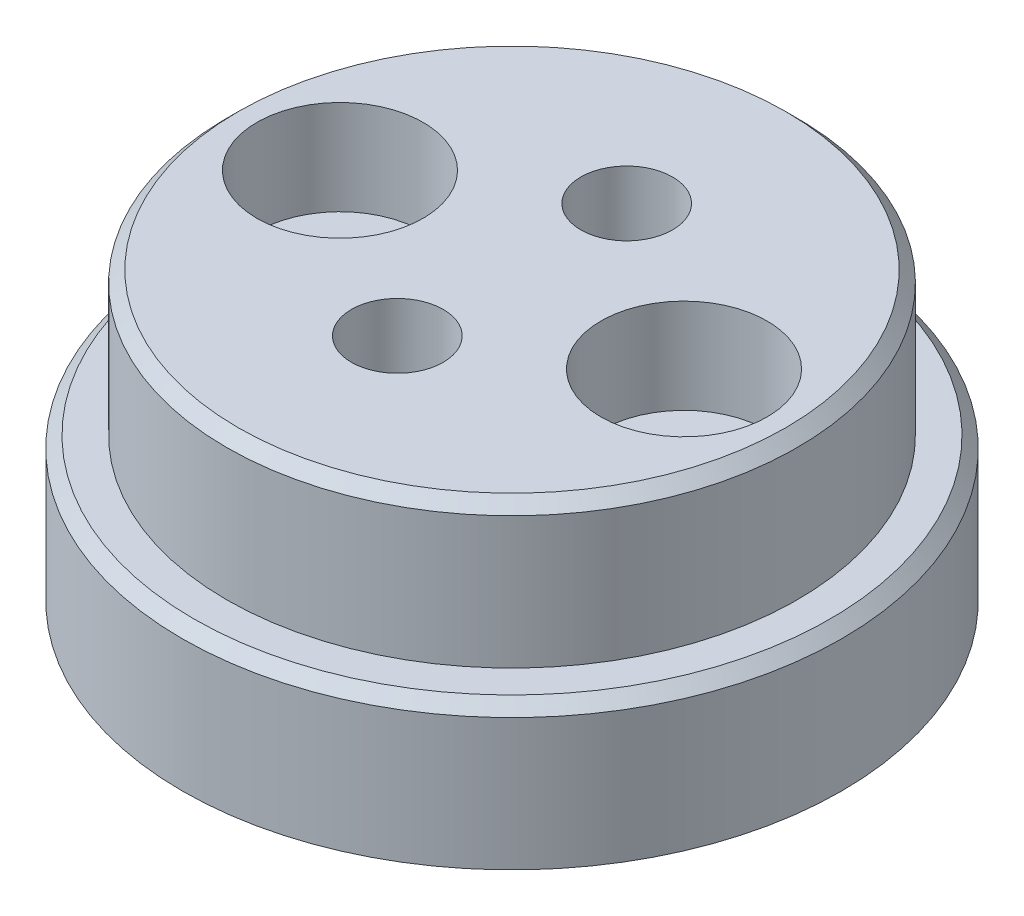
from build123d import *

# Parameters (mm, degrees)
ESQUISSE1_R             = 11.5
ESQUISSE1_R_2           = 1.7
ESQUISSE1_R_3           = 1.6
BOSS_EXTRU_1_DEPTH      = 5
ESQUISSE2_R             = 9.95
ESQUISSE2_R_2           = 1.7
ESQUISSE2_R_3           = 1.6
BOSS_EXTRU_2_DEPTH      = 5
CHANFREIN2_SIZE         = 0.4
CHANFREIN4_SIZE         = 0.4
ESQUISSE3_R             = 2.2
ENL_V_MAT_EXTRU_1_DEPTH = 5.7
ESQUISSE4_R             = 2.9
ENL_V_MAT_EXTRU_2_DEPTH = 3.3


with BuildPart() as part:
    # Esquisse1 → Boss.-Extru.1 (new body)
    with BuildSketch(Plane(origin=(0, 0, 0), x_dir=(1, 0, 0), z_dir=(0, 1, 0))):
        Circle(ESQUISSE1_R)
        with Locations((6, 0)):
            Circle(ESQUISSE1_R_2, mode=Mode.SUBTRACT)
        with Locations((-6, 0)):
            Circle(ESQUISSE1_R_2, mode=Mode.SUBTRACT)
        with Locations((0, 4)):
            Circle(ESQUISSE1_R_3, mode=Mode.SUBTRACT)
        with Locations((0, -4)):
            Circle(ESQUISSE1_R_3, mode=Mode.SUBTRACT)
    extrude(amount=BOSS_EXTRU_1_DEPTH)

    # Esquisse2 → Boss.-Extru.2 (add)
    with BuildSketch(Plane(origin=(0, 5, 0), x_dir=(1, 0, 0), z_dir=(0, 1, 0))):
        Circle(ESQUISSE2_R)
        with Locations((6, 0)):
            Circle(ESQUISSE2_R_2, mode=Mode.SUBTRACT)
        with Locations((-6, 0)):
            Circle(ESQUISSE2_R_2, mode=Mode.SUBTRACT)
        with Locations((0, -4)):
            Circle(ESQUISSE2_R_3, mode=Mode.SUBTRACT)
        with Locations((0, 4)):
            Circle(ESQUISSE2_R_3, mode=Mode.SUBTRACT)
    extrude(amount=BOSS_EXTRU_2_DEPTH)

    # Chanfrein2
    chanfrein2_edges = [part.edges().sort_by_distance(p)[0] for p in [
        (-9.95, 10, 0),
    ]]
    chamfer(chanfrein2_edges, length=CHANFREIN2_SIZE)

    # Chanfrein4
    chanfrein4_edges = [part.edges().sort_by_distance(p)[0] for p in [
        (-11.5, 5, 0),
    ]]
    chamfer(chanfrein4_edges, length=CHANFREIN4_SIZE)

    # Esquisse3 → Enlèv. mat.-Extru.1 (cut)
    with BuildSketch(Plane.XZ):
        with Locations((0, -4)):
            Circle(ESQUISSE3_R)
        with Locations((0, 4)):
            Circle(ESQUISSE3_R)
    extrude(amount=-ENL_V_MAT_EXTRU_1_DEPTH, mode=Mode.SUBTRACT)

    # Esquisse4 → Enlèv. mat.-Extru.2 (cut)
    with BuildSketch(Plane(origin=(0, 10, 0), x_dir=(1, 0, 0), z_dir=(0, 1, 0))):
        with Locations((-6, 0)):
            Circle(ESQUISSE4_R)
        with Locations((6, 0)):
            Circle(ESQUISSE4_R)
    extrude(amount=-ENL_V_MAT_EXTRU_2_DEPTH, mode=Mode.SUBTRACT)


solid = part.part
